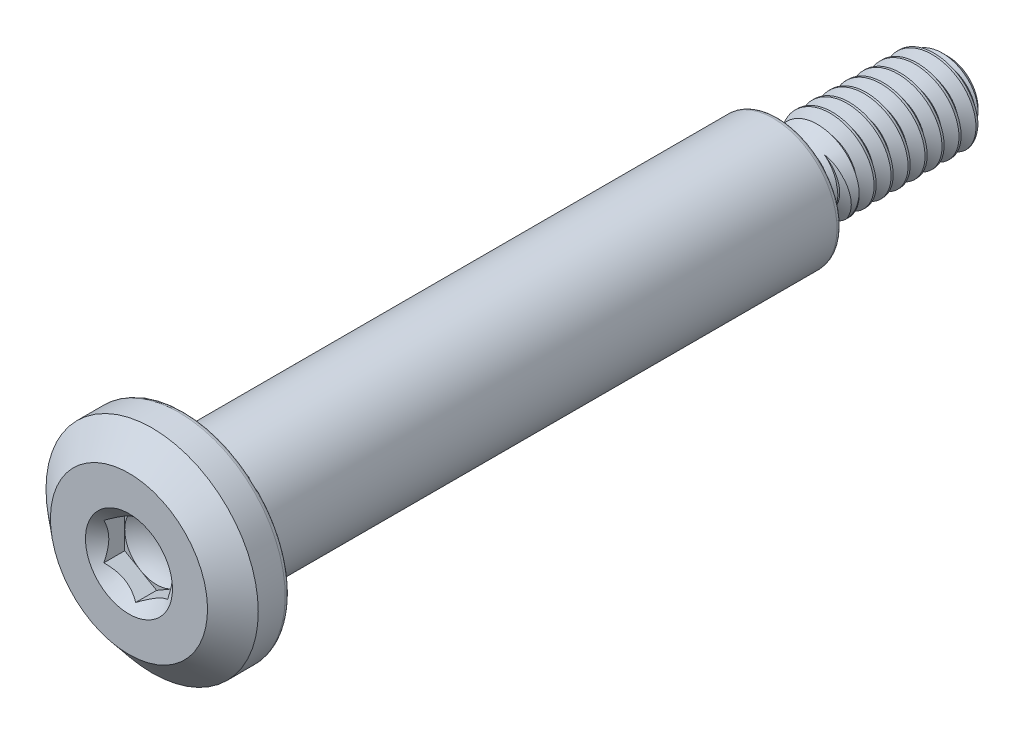
from build123d import *

# Parameters (mm, degrees)
CUT_EXTRUDE2_DEPTH     = 0.65
SKETCH9_R              = 1.025
CUT_EXTRUDE4_DEPTH     = 0.65
CUT_EXTRUDE4_DRAFT     = -45.0000000000001
CHAMFER1_SIZE          = 0.30000000000000004
CHAMFER2_SIZE          = 0.65
CHAMFER2_SIZE2         = 0.5454147602652337
FILLET1_R              = 0.12
FILLET2_R              = 0.11249999999999999
CUT_SWEEP1_PITCH       = 0.3999999999999975
CUT_SWEEP1_HEIGHT      = 3.799999999999991
CUT_SWEEP1_RADIUS      = 1.000000000000014
CUT_SWEEP1_START_ANGLE = 6.36e-15


with BuildPart() as part:
    # Sketch10 → Revolve1 (revolve)
    with BuildSketch(Plane(origin=(0, 0, 0), x_dir=(0, 0, -1), z_dir=(1, 0, 0))):
        Polygon((15.300000000000006, 1.4999999999999856), (15.299999999999997, 1.0000000000000036), (19.299999999999997, 1.000000000000004), (19.3, -1.3e-15), (0, 0), (1.41e-15, 2.5000000000000004), (1.3000000000000007, 2.4999999999999987), (1.3000000000000043, 1.4999999999999944), align=None)
    revolve(axis=Axis((0, -1.3e-15, -19.3), (0, 7e-17, 1)))

    # Sketch5 → Cut-Revolve1 (revolve, cut)
    with BuildSketch(Plane(origin=(0, 0, 0), x_dir=(0, 0, -1), z_dir=(1, 0, 0))):
        with BuildLine():
            Line((15.3, 1.4999999999999982), (16.700000000000003, 1.4999999999999982))
            Line((16.700000000000003, 1.4999999999999982), (15.85, 0.6500000000000019))
            Line((15.85, 0.6500000000000019), (15.475000000000003, 0.6500000000000024))
            ThreePointArc((15.475000000000003, 0.6500000000000024), (15.351256313292357, 0.7012563132923564), (15.300000000000002, 0.8250000000000027))
            Line((15.300000000000002, 0.8250000000000027), (15.3, 1.4999999999999982))
        make_face()
    revolve(axis=Axis((0, -1.3e-15, -19.3), (0, 7e-17, 1)), mode=Mode.SUBTRACT)

    # Sketch8 → Cut-Extrude2 (cut)
    with BuildSketch(Plane.XY):
        Polygon((-5.2e-16, 0.866025403784438), (-0.7500000000000011, 0.4330127018922188), (-0.7500000000000011, -0.43301270189221797), (2e-17, -0.8660254037844376), (0.7499999999999993, -0.43301270189221835), (0.7499999999999993, 0.4330127018922197), align=None)
    extrude(amount=-CUT_EXTRUDE2_DEPTH, mode=Mode.SUBTRACT)


with BuildPart() as cut_extrude4_tool:
    # Sketch9 → Cut-Extrude4 (with draft: the straight prism first)
    with BuildSketch(Plane.XY):
        Circle(SKETCH9_R)
    extrude(amount=-CUT_EXTRUDE4_DEPTH)
    # Cut-Extrude4: the draft: its side faces are tilted about the plane it starts from
    cut_extrude4_sides = [cut_extrude4_tool.faces().sort_by_distance(p)[0] for p in [
        (-1.025, 0, -0.325),
    ]]
    draft(cut_extrude4_sides, Plane.XY, CUT_EXTRUDE4_DRAFT)


with BuildPart() as part_1:
    add(part.part)

    # Cut-Extrude4: cut by cut_extrude4_tool
    add(cut_extrude4_tool.part, mode=Mode.SUBTRACT)

    # Chamfer1
    chamfer1_edges = [part_1.edges().sort_by_distance(p)[0] for p in [
        (-1.2e-16, -1.0000000000000067, -19.299999999999997),
    ]]
    chamfer(chamfer1_edges, length=CHAMFER1_SIZE)

    # Chamfer2
    chamfer2_edges = [part_1.edges().sort_by_distance(p)[0] for p in [
        (-3.1e-16, -2.5000000000000004, 1.7e-16),
    ]]
    chamfer2_side = [part_1.faces().sort_by_distance(p)[0] for p in [
        (-3e-16, -2.429289321881346, 1.6e-16),
    ]]
    chamfer(chamfer2_edges, length=CHAMFER2_SIZE, length2=CHAMFER2_SIZE2, reference=chamfer2_side[0])

    # Sketch12 → Cut-Revolve5 (revolve, cut)
    with BuildSketch(Plane(origin=(0, 0, 0), x_dir=(0, 0, -1), z_dir=(1, 0, 0)), mode=Mode.PRIVATE) as cut_revolve5_sk:
        Polygon((1.3000000000000043, 1.4999999999999944), (1.8540000000000043, 1.4999999999999942), (1.3000000000000043, 1.242), align=None)
    revolve(cut_revolve5_sk.sketch.rotate(Axis((0, 0, 0), (0, -5e-16, -1)), 180), axis=Axis((0, 0, 0), (0, -5e-16, -1)), mode=Mode.SUBTRACT)

    # Sketch13 → Cut-Revolve6 (revolve, cut)
    with BuildSketch(Plane(origin=(0, 0, 0), x_dir=(1, 0, 0), z_dir=(0, 1, 0)), mode=Mode.PRIVATE) as cut_revolve6_sk:
        with BuildLine():
            Line((-5.2e-16, 0.65), (0, 0.9039999999999999))
            ThreePointArc((0, 0.9039999999999999), (0.39592170943255894, 0.8387767010803919), (0.7499999999999993, 0.65))
            Line((0.7499999999999993, 0.65), (-5.2e-16, 0.65))
        make_face()
    revolve(cut_revolve6_sk.sketch.rotate(Axis((-5.2e-16, 0, -0.65), (2.03e-15, 0, -1)), 90), axis=Axis((-5.2e-16, 0, -0.65), (2.03e-15, 0, -1)), mode=Mode.SUBTRACT)

    # Fillet1
    fillet1_edges = [part_1.edges().sort_by_distance(p)[0] for p in [
        (-3.1e-16, -2.4999999999999987, -1.3000000000000005),
        (-1.8e-16, -1.4999999999999878, -15.300000000000006),
    ]]
    fillet(fillet1_edges, radius=FILLET1_R)

    # Fillet2
    fillet2_edges = [part_1.edges().sort_by_distance(p)[0] for p in [
        (-3e-16, 1.242, -1.3000000000000043),
    ]]
    fillet(fillet2_edges, radius=FILLET2_R)

    # Cut-Sweep1: sweep along a helix
    with BuildLine() as cut_sweep1_path:
        add(Helix(CUT_SWEEP1_PITCH, CUT_SWEEP1_HEIGHT, CUT_SWEEP1_RADIUS, center=(0, -1.26e-15, -19.299999999999997), direction=(0, -7e-17, 1), mode=Mode.PRIVATE).rotate(Axis((0, -1.26e-15, -19.299999999999997), (0, -7e-17, 1)), CUT_SWEEP1_START_ANGLE))
    with BuildLine() as cut_sweep1_axis:
        Line((0, -1.26e-15, -19.299999999999997), (0, -1.51e-15, -15.500000000000007))
    # Sketch4 → Cut-Sweep1 (sweep, cut)
    with BuildSketch(Plane(origin=(0, 0, 0), x_dir=(0, 0, -1), z_dir=(1, 0, 0))):
        Polygon((19.450000000000003, 0.7401923788646669), (19.500000000000004, 0.7401923788646669), (19.662500000000005, 1.0216506350946133), (19.287499999999998, 1.0216506350946133), align=None)
    sweep(path=cut_sweep1_path.line, binormal=cut_sweep1_axis.edges()[0], mode=Mode.SUBTRACT)


solid = part_1.part
